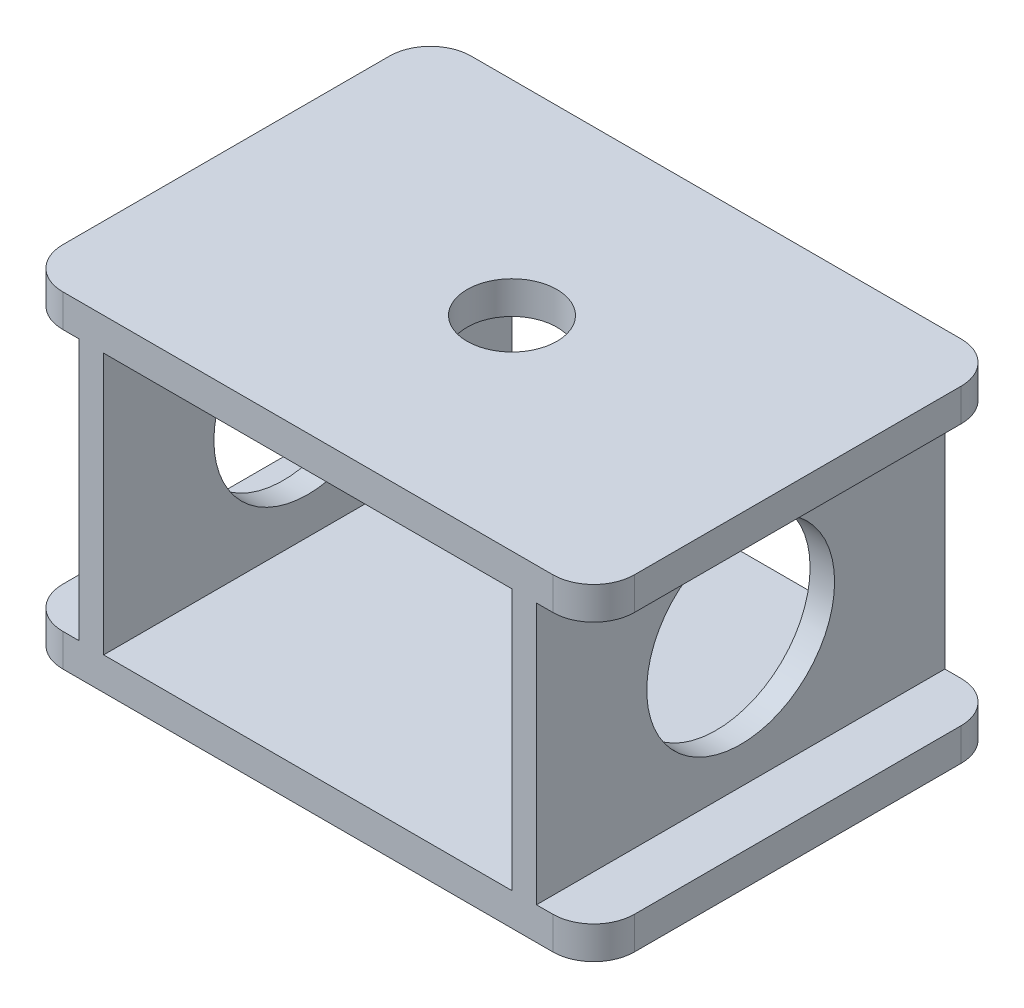
from build123d import *

# Parameters (mm, degrees)
BOSS_EXTRUDE1_DEPTH = 4
SKETCH2_W           = 3
SKETCH2_H           = 50
BOSS_EXTRUDE4_DEPTH = 32
SKETCH4_W           = 50
SKETCH4_H           = 50
SKETCH4_W_2         = 3
BOSS_EXTRUDE5_DEPTH = 4
SKETCH6_R           = 11.5
CUT_EXTRUDE1_DEPTH  = 106
SKETCH7_R           = 5.5
CUT_EXTRUDE2_DEPTH  = 10


with BuildPart() as part:
    # Sketch1 → Boss-Extrude1 (new body)
    with BuildSketch(Plane(origin=(0, 0, 0), x_dir=(1, 0, 0), z_dir=(0, 1, 0))):
        with BuildLine():
            Line((-30, 25), (30, 25))
            ThreePointArc((30, 25), (33.535533906, 23.535533906), (35, 20))
            Line((35, 20), (35, -20))
            ThreePointArc((35, -20), (33.535533906, -23.535533906), (30, -25))
            Line((30, -25), (-30, -25))
            ThreePointArc((-30, -25), (-33.535533906, -23.535533906), (-35, -20))
            Line((-35, -20), (-35, 20))
            ThreePointArc((-35, 20), (-33.535533906, 23.535533906), (-30, 25))
        make_face()
    extrude(amount=BOSS_EXTRUDE1_DEPTH)

    # Sketch2 → Boss-Extrude4 (add)
    with BuildSketch(Plane(origin=(0, 4, 0), x_dir=(1, 0, 0), z_dir=(0, 1, 0))):
        with Locations((-26.5, 0)):
            Rectangle(SKETCH2_W, SKETCH2_H)
        with Locations((26.5, 0)):
            Rectangle(SKETCH2_W, SKETCH2_H)
    extrude(amount=BOSS_EXTRUDE4_DEPTH)

    # Sketch4 → Boss-Extrude5 (add)
    with BuildSketch(Plane(origin=(0, 36, 0), x_dir=(1, 0, 0), z_dir=(0, 1, 0))):
        Rectangle(SKETCH4_W, SKETCH4_H)
        with BuildLine():
            Line((-35, 20), (-35, -20))
            ThreePointArc((-35, -20), (-33.535533906, -23.535533906), (-30, -25))
            Line((-30, -25), (-28, -25))
            Line((-28, -25), (-28, 25))
            Line((-28, 25), (-30, 25))
            ThreePointArc((-30, 25), (-33.535533906, 23.535533906), (-35, 20))
        make_face()
        with BuildLine():
            Line((35, -20), (35, 20))
            ThreePointArc((35, 20), (33.535533906, 23.535533906), (30, 25))
            Line((30, 25), (28, 25))
            Line((28, 25), (28, -25))
            Line((28, -25), (30, -25))
            ThreePointArc((30, -25), (33.535533906, -23.535533906), (35, -20))
        make_face()
        with Locations((26.5, 0)):
            Rectangle(SKETCH4_W_2, SKETCH4_H)
        with Locations((-26.5, 0)):
            Rectangle(SKETCH4_W_2, SKETCH4_H)
    extrude(amount=BOSS_EXTRUDE5_DEPTH)

    # Sketch6 → Cut-Extrude1 (cut)
    with BuildSketch(Plane(origin=(28, 0, 0), x_dir=(0, 0, -1), z_dir=(1, 0, 0))):
        with Locations((0, 20)):
            Circle(SKETCH6_R)
    extrude(amount=-CUT_EXTRUDE1_DEPTH, mode=Mode.SUBTRACT)

    # Sketch7 → Cut-Extrude2 (cut)
    with BuildSketch(Plane(origin=(0, 40, 0), x_dir=(1, 0, 0), z_dir=(0, 1, 0))):
        Circle(SKETCH7_R)
    extrude(amount=-CUT_EXTRUDE2_DEPTH, mode=Mode.SUBTRACT)


solid = part.part
